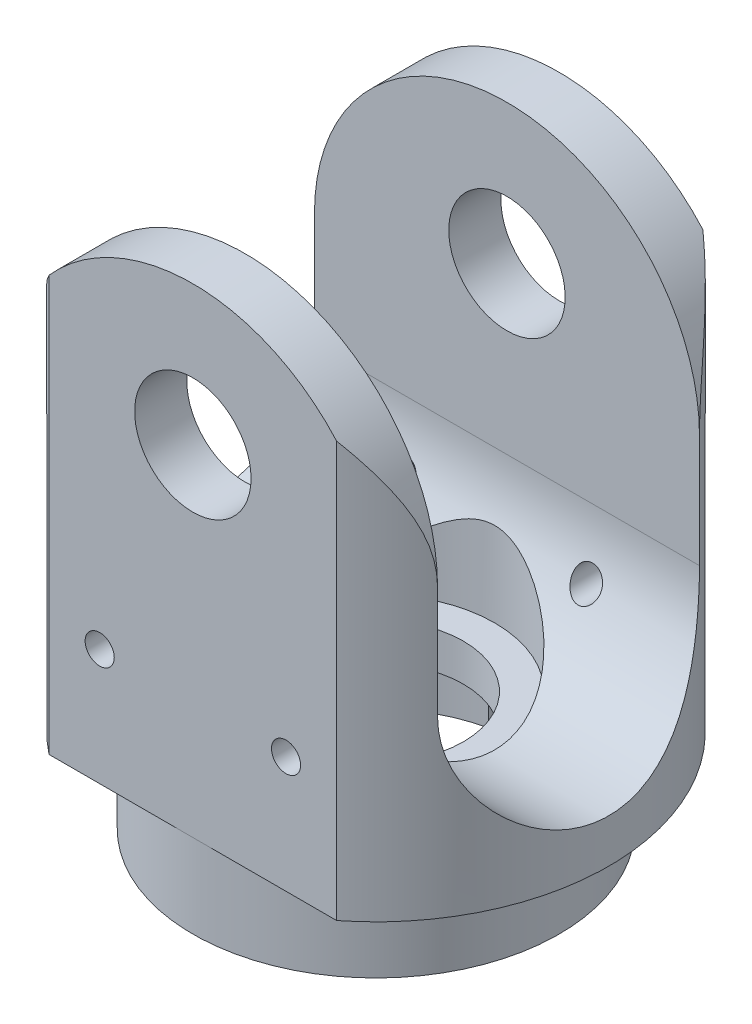
from build123d import *

# Parameters (mm, degrees)
SKETCH1_R                = 12.7
BOSS_EXTRUDE1_DEPTH      = 15.367
BOSS_EXTRUDE1_DEPTH_BACK = 15.367
SKETCH4_W                = 25.4
SKETCH4_H                = 30.734
CUT_EXTRUDE2_DEPTH       = 3.71145
SKETCH5_W                = 14.2875
SKETCH5_H                = 16.637
CUT_EXTRUDE3_DEPTH       = 13.7
CUT_EXTRUDE3_DEPTH_BACK  = 13.7
CUT_EXTRUDE4_DEPTH       = 20.9771001
SKETCH7_R                = 4.7625
CUT_EXTRUDE5_DEPTH       = 31.7340001
SKETCH9_R                = 17.852773039
SKETCH9_R_2              = 9.9822
CUT_EXTRUDE6_DEPTH       = 4.572
SKETCH10_R               = 6.477
CUT_EXTRUDE7_DEPTH       = 24.257
SKETCH11_R               = 3.175
CUT_EXTRUDE8_DEPTH       = 20.9771001
SKETCH12_R               = 0.79375
CUT_EXTRUDE9_DEPTH       = 1.0000001
CUT_EXTRUDE9_DEPTH_BACK  = 20.9771001
SKETCH15_R               = 4.7625
CUT_EXTRUDE12_DEPTH      = 4.445
SKETCH16_R               = 1.5875
CUT_EXTRUDE13_DEPTH      = 4.445


with BuildPart() as part:
    # Sketch1 → Boss-Extrude1 (new body, two sides)
    with BuildSketch(Plane(origin=(0, 0, 0), x_dir=(1, 0, 0), z_dir=(0, 1, 0))) as boss_extrude1_sk:
        Circle(SKETCH1_R)
    extrude(amount=BOSS_EXTRUDE1_DEPTH)
    extrude(boss_extrude1_sk.sketch, amount=-BOSS_EXTRUDE1_DEPTH_BACK)

    # Sketch4 → Cut-Extrude2 (cut, through all)
    with BuildSketch(Plane.XY.offset(9.98855)):
        Rectangle(SKETCH4_W, SKETCH4_H)
    cut_extrude2 = extrude(amount=CUT_EXTRUDE2_DEPTH, mode=Mode.SUBTRACT)

    # Mirror2: Cut-Extrude2 across plane
    add(cut_extrude2.mirror(Plane.XY), mode=Mode.SUBTRACT)

    # Sketch5 → Cut-Extrude3 (cut, two sides)
    with BuildSketch(Plane(origin=(0, 0, 0), x_dir=(0, 0, -1), z_dir=(1, 0, 0))) as cut_extrude3_sk:
        with Locations((0, 7.0485)):
            Rectangle(SKETCH5_W, SKETCH5_H)
        with BuildLine():
            Line((7.14375, -1.27), (-7.14375, -1.27))
            ThreePointArc((-7.14375, -1.27), (0, -8.41375), (7.14375, -1.27))
        make_face()
    extrude(amount=CUT_EXTRUDE3_DEPTH, mode=Mode.SUBTRACT)
    extrude(cut_extrude3_sk.sketch, amount=-CUT_EXTRUDE3_DEPTH_BACK, mode=Mode.SUBTRACT)

    # Sketch6 → Cut-Extrude4 (cut, through all)
    with BuildSketch(Plane.XY.offset(9.98855)):
        with BuildLine():
            ThreePointArc((7.843396515, 11.847950137), (9.813665145, 8.601547837), (10.50036, 4.86664))
            Line((10.50036, 4.86664), (14.849727138, 4.86664))
            ThreePointArc((14.849727138, 4.86664), (0, 19.716367138), (-14.849727138, 4.86664))
            Line((-14.849727138, 4.86664), (-10.50036, 4.86664))
            ThreePointArc((-10.50036, 4.86664), (-9.813665145, 8.601547837), (-7.843396515, 11.847950137))
            Line((-7.843396515, 11.847950137), (-7.843396515, 15.367))
            Line((-7.843396515, 15.367), (0, 15.367))
            Line((0, 15.367), (7.843396515, 15.367))
            Line((7.843396515, 15.367), (7.843396515, 11.847950137))
        make_face()
        with BuildLine():
            ThreePointArc((-7.843396515, 11.847950137), (-4.298330514, 14.446927831), (0, 15.367))
            Line((0, 15.367), (-7.843396515, 15.367))
            Line((-7.843396515, 15.367), (-7.843396515, 11.847950137))
        make_face()
        with BuildLine():
            ThreePointArc((0, 15.367), (4.298330514, 14.446927831), (7.843396515, 11.847950137))
            Line((7.843396515, 11.847950137), (7.843396515, 15.367))
            Line((7.843396515, 15.367), (0, 15.367))
        make_face()
    extrude(amount=-CUT_EXTRUDE4_DEPTH, mode=Mode.SUBTRACT)

    # Sketch7 → Cut-Extrude5 (cut, through all)
    with BuildSketch(Plane.XZ.offset(15.367)):
        Circle(SKETCH7_R)
    extrude(amount=-CUT_EXTRUDE5_DEPTH, mode=Mode.SUBTRACT)

    # Sketch9 → Cut-Extrude6 (cut)
    with BuildSketch(Plane.XZ.offset(15.367)):
        Circle(SKETCH9_R)
        Circle(SKETCH9_R_2, mode=Mode.SUBTRACT)
    extrude(amount=-CUT_EXTRUDE6_DEPTH, mode=Mode.SUBTRACT)

    # Sketch10 → Cut-Extrude7 (cut)
    with BuildSketch(Plane(origin=(0, 15.367, 0), x_dir=(1, 0, 0), z_dir=(0, 1, 0))):
        Circle(SKETCH10_R)
    extrude(amount=-CUT_EXTRUDE7_DEPTH, mode=Mode.SUBTRACT)

    # Sketch11 → Cut-Extrude8 (cut, through all)
    with BuildSketch(Plane.XY.offset(9.98855)):
        with Locations((0, 7.747)):
            Circle(SKETCH11_R)
    extrude(amount=-CUT_EXTRUDE8_DEPTH, mode=Mode.SUBTRACT)

    # Sketch12 → Cut-Extrude9 (cut, two sides)
    with BuildSketch(Plane(origin=(0, 0, -9.98855), x_dir=(-1, 0, 0), z_dir=(0, 0, -1))) as cut_extrude9_sk:
        with Locations((5.081146515, -4.445)):
            Circle(SKETCH12_R)
        with Locations((-5.081146515, -4.445)):
            Circle(SKETCH12_R)
    extrude(amount=CUT_EXTRUDE9_DEPTH, mode=Mode.SUBTRACT)
    extrude(cut_extrude9_sk.sketch, amount=-CUT_EXTRUDE9_DEPTH_BACK, mode=Mode.SUBTRACT)

    # Sketch15 → Cut-Extrude12 (cut)
    with BuildSketch(Plane.XZ.offset(15.367)):
        with BuildLine():
            ThreePointArc((8.001, 0), (-5.572105758, 5.741745241), (-0.239879494, -7.997403255))
            Line((-0.239879494, -7.997403255), (7.597144444, -2.509860017))
            ThreePointArc((7.597144444, -2.509860017), (7.899390916, -1.271072049), (8.001, 0))
        make_face()
        Circle(SKETCH15_R, mode=Mode.SUBTRACT)
    extrude(amount=-CUT_EXTRUDE12_DEPTH, mode=Mode.SUBTRACT)

    # Sketch16 → Cut-Extrude13 (cut)
    with BuildSketch(Plane.XZ.offset(15.367)):
        with Locations((-0.217023554, -7.235403255)):
            Circle(SKETCH16_R)
        with Locations((6.873606877, -2.270825729)):
            Circle(SKETCH16_R)
    extrude(amount=-CUT_EXTRUDE13_DEPTH, mode=Mode.SUBTRACT)


solid = part.part
